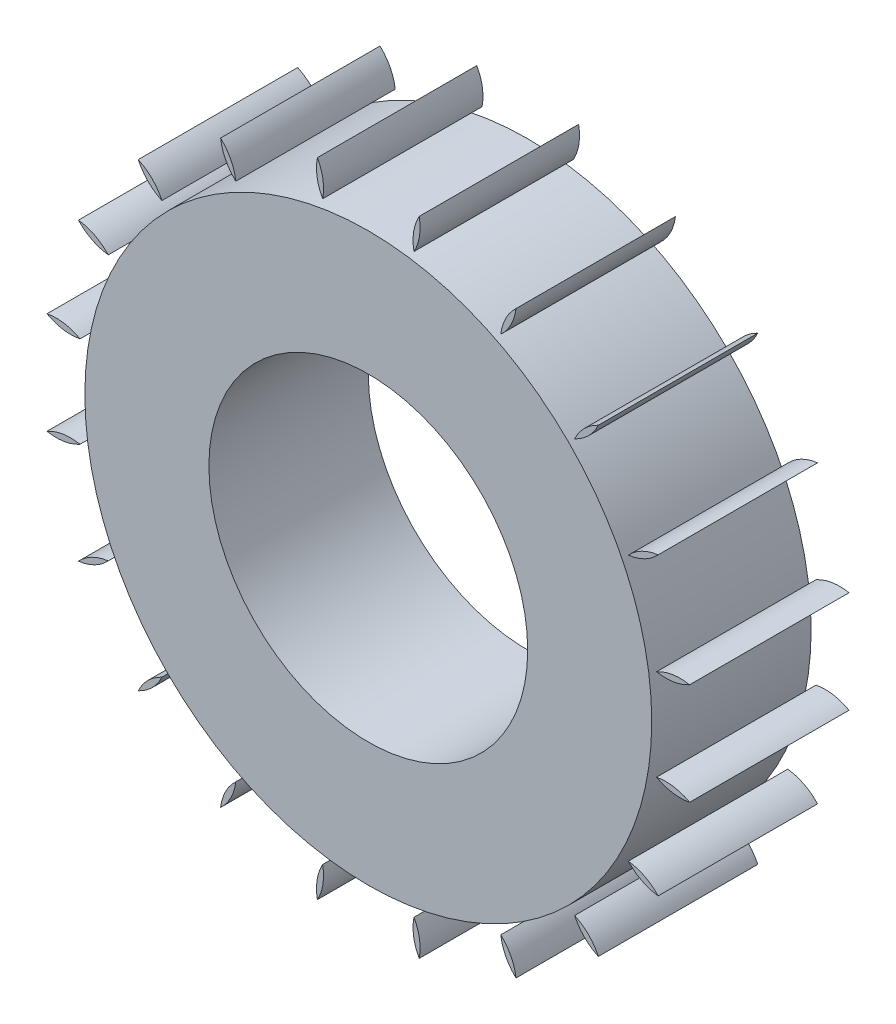
from build123d import *

# Parameters (mm, degrees)
SKETCH1_R           = 13.2
SKETCH1_R_2         = 6
BOSS_EXTRUDE1_DEPTH = 6
CUT_EXTRUDE1_DEPTH  = 7
CIRPATTERN2_COUNT   = 20


with BuildPart() as part:
    # Sketch1 → Boss-Extrude1 (new body)
    with BuildSketch(Plane.XY):
        Circle(SKETCH1_R)
        Circle(SKETCH1_R_2, mode=Mode.SUBTRACT)
    extrude(amount=BOSS_EXTRUDE1_DEPTH)

    # Sketch2 → Cut-Extrude1 (cut, through all)
    with BuildSketch(Plane.XY.offset(6)):
        with BuildLine():
            ThreePointArc((-2.819851171, 12.895287487), (0, 13.2), (2.819851171, 12.895287487))
            ThreePointArc((2.819851171, 12.895287487), (1.826256171, 11.910750525), (1.819851171, 10.512))
            ThreePointArc((1.819851171, 10.512), (0, 10.668364555), (-1.819851171, 10.512))
            ThreePointArc((-1.819851171, 10.512), (-1.826256171, 11.910750525), (-2.819851171, 12.895287487))
        make_face()
    cut_extrude1 = extrude(amount=-CUT_EXTRUDE1_DEPTH, mode=Mode.SUBTRACT)

    # CirPattern2: Cut-Extrude1 ×20 about axis
    cirpattern2_axis = Axis((0, 0, 0), (0, 0, 1))
    for i in range(1, CIRPATTERN2_COUNT):
        add(cut_extrude1.rotate(cirpattern2_axis, i * 360 / CIRPATTERN2_COUNT), mode=Mode.SUBTRACT)


solid = part.part
